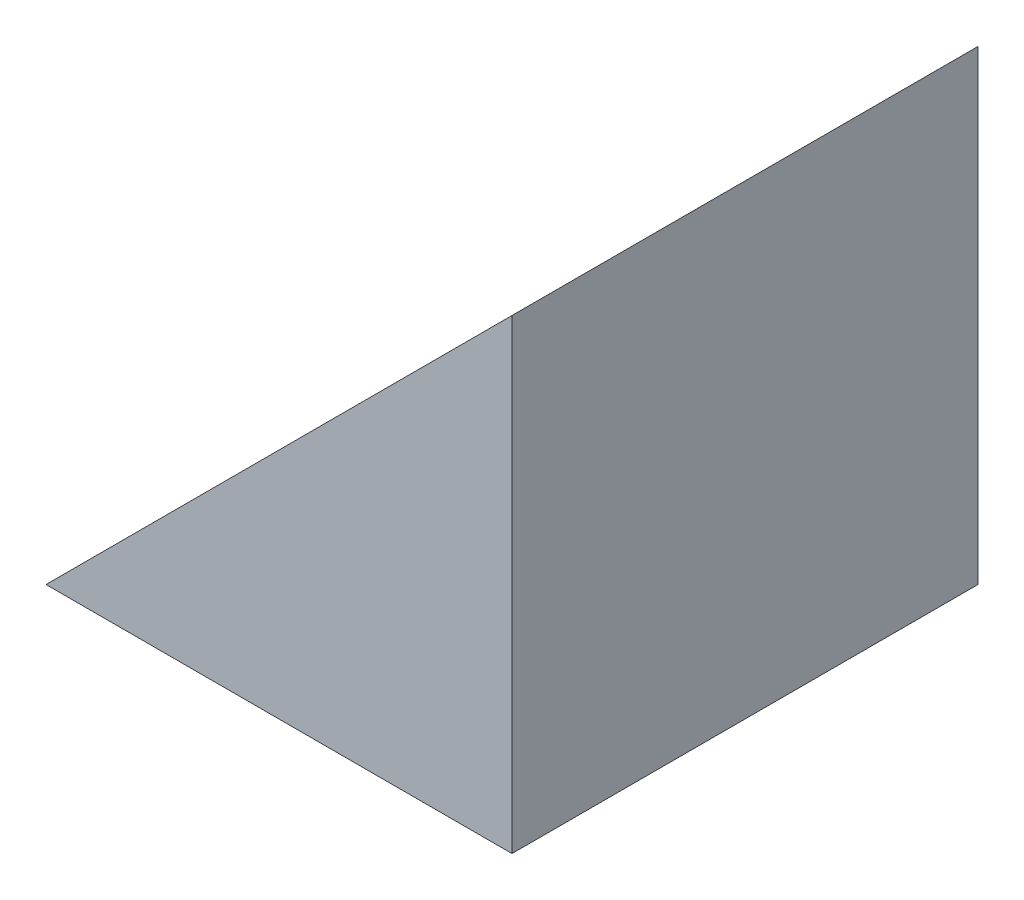
from build123d import *

# Parameters (mm, degrees)
EXTRUDE_1_DEPTH = 50


with BuildPart() as part:
    # 草图1 → 凸台-拉伸1 (new body)
    with BuildSketch(Plane.XY):
        Polygon((174.714063711, 132.77907024), (174.714063711, 182.77907024), (124.714063711, 132.77907024), align=None)
    extrude(amount=EXTRUDE_1_DEPTH)


solid = part.part
